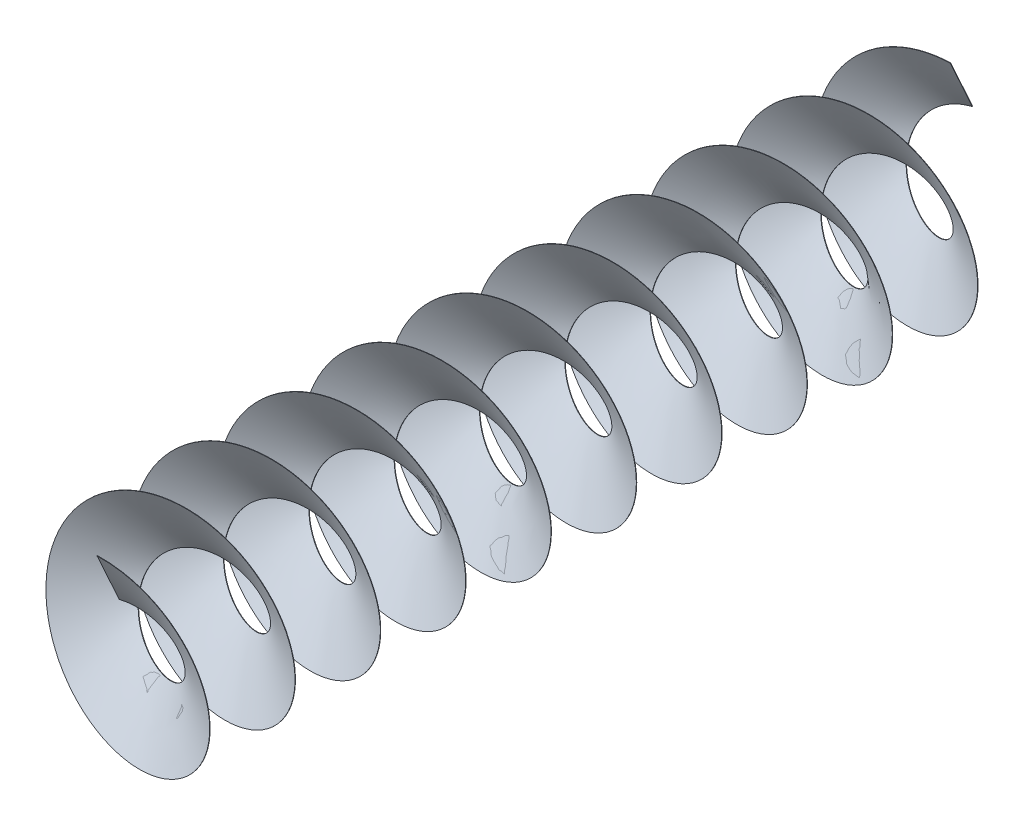
from build123d import *

# Parameters (mm, degrees)
AUSTRAGUNG1_PITCH       = 50
AUSTRAGUNG1_HEIGHT      = 500
AUSTRAGUNG1_RADIUS      = 25
AUSTRAGUNG1_START_ANGLE = 90


with BuildPart() as part:
    # Austragung1: sweep along a helix
    with BuildLine() as austragung1_path:
        add(Helix(AUSTRAGUNG1_PITCH, AUSTRAGUNG1_HEIGHT, AUSTRAGUNG1_RADIUS, center=(0, 0, 0), direction=(0, 0, -1), mode=Mode.PRIVATE).rotate(Axis((0, 0, 0), (0, 0, -1)), AUSTRAGUNG1_START_ANGLE))
    # Skizze2 → Austragung1 (sweep)
    with BuildSketch(Plane(origin=(0, 25, 0), x_dir=(-0.303314471, 0, -0.952890514), z_dir=(0.952890514, 0, -0.303314471))):
        Polygon((0, 0), (-0.25, 0), (-20.25, 34.641016151), (-20, 34.641016151), align=None)
    sweep(path=austragung1_path.line, is_frenet=True)


solid = part.part
